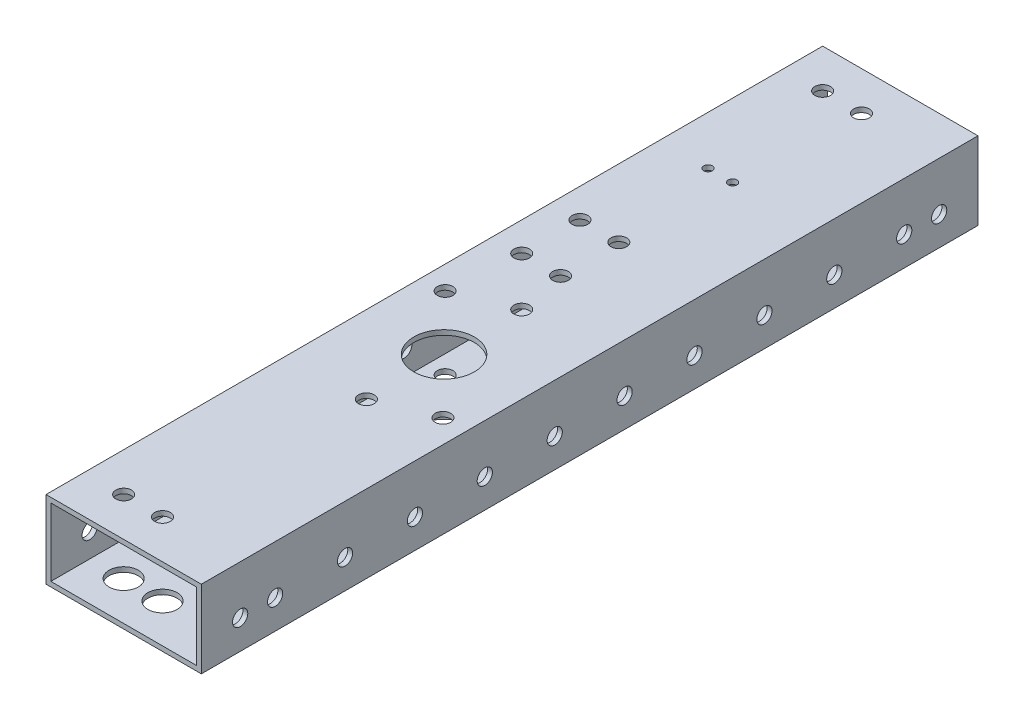
from build123d import *

# Parameters (mm, degrees)
SKETCH1_W           = 50.8
SKETCH1_H           = 25.4
SKETCH1_W_2         = 47.625
SKETCH1_H_2         = 22.225
BOSS_EXTRUDE1_DEPTH = 127
SKETCH3_R           = 2.5527
CUT_EXTRUDE1_DEPTH  = 1.5875
SKETCH5_R           = 4.7625
SKETCH5_R_2         = 2.5527
CUT_EXTRUDE2_DEPTH  = 1.5875
SKETCH6_R           = 2.4892
CUT_EXTRUDE3_DEPTH  = 138.371503595
SKETCH11_R          = 9.906
SKETCH11_R_2        = 2.5527
SKETCH11_R_3        = 1.4224
CUT_EXTRUDE4_DEPTH  = 132.982271537


with BuildPart() as part:
    # Sketch1 → Boss-Extrude1 (new, symmetric)
    with BuildSketch(Plane.XY):
        Rectangle(SKETCH1_W, SKETCH1_H)
        Rectangle(SKETCH1_W_2, SKETCH1_H_2, mode=Mode.SUBTRACT)
    extrude(amount=BOSS_EXTRUDE1_DEPTH, both=True)

    # Sketch3 → Cut-Extrude1 (cut)
    with BuildSketch(Plane(origin=(0, 12.7, 0), x_dir=(1, 0, 0), z_dir=(0, 1, 0))):
        with Locations(Location((-12.7, -114.3, 0), (0, 0, 270))):
            Circle(SKETCH3_R)
        with Locations(Location((0, -114.3, 0), (0, 0, 270))):
            Circle(SKETCH3_R)
        with Locations(Location((-12.7, 114.3, 0), (0, 0, 270))):
            Circle(SKETCH3_R)
        with Locations(Location((0, 114.3, 0), (0, 0, 270))):
            Circle(SKETCH3_R)
    extrude(amount=-CUT_EXTRUDE1_DEPTH, mode=Mode.SUBTRACT)

    # Sketch5 → Cut-Extrude2 (cut)
    with BuildSketch(Plane.XZ.offset(12.7)):
        with Locations(Location((0, -114.3, 0), (0, 0, 270))):
            Circle(SKETCH5_R)
        with Locations(Location((0, -114.3, 0), (0, 0, 90))):
            Circle(SKETCH5_R_2, mode=Mode.SUBTRACT)
        with Locations(Location((0, -114.3, 0), (0, 0, 90))):
            Circle(SKETCH5_R_2)
        with Locations(Location((-12.7, -114.3, 0), (0, 0, 270))):
            Circle(SKETCH5_R)
        with Locations(Location((-12.7, -114.3, 0), (0, 0, 90))):
            Circle(SKETCH5_R_2, mode=Mode.SUBTRACT)
        with Locations(Location((-12.7, -114.3, 0), (0, 0, 90))):
            Circle(SKETCH5_R_2)
        with Locations(Location((0, 114.3, 0), (0, 0, 270))):
            Circle(SKETCH5_R)
        with Locations(Location((0, 114.3, 0), (0, 0, 90))):
            Circle(SKETCH5_R_2, mode=Mode.SUBTRACT)
        with Locations(Location((0, 114.3, 0), (0, 0, 90))):
            Circle(SKETCH5_R_2)
        with Locations(Location((-12.7, 114.3, 0), (0, 0, 270))):
            Circle(SKETCH5_R)
        with Locations(Location((-12.7, 114.3, 0), (0, 0, 90))):
            Circle(SKETCH5_R_2, mode=Mode.SUBTRACT)
        with Locations(Location((-12.7, 114.3, 0), (0, 0, 90))):
            Circle(SKETCH5_R_2)
    extrude(amount=-CUT_EXTRUDE2_DEPTH, mode=Mode.SUBTRACT)

    # Sketch6 → Cut-Extrude3 (cut, through all)
    with BuildSketch(Plane(origin=(25.4, 0, 0), x_dir=(0, 0, -1), z_dir=(1, 0, 0))):
        with Locations((-114.3, -3.175)):
            Circle(SKETCH6_R)
        with Locations((114.3, -3.175)):
            Circle(SKETCH6_R)
        with Locations((-102.87, -3.175)):
            Circle(SKETCH6_R)
        with Locations((-80.01, -3.175)):
            Circle(SKETCH6_R)
        with Locations((-57.15, -3.175)):
            Circle(SKETCH6_R)
        with Locations((-34.29, -3.175)):
            Circle(SKETCH6_R)
        with Locations((-11.43, -3.175)):
            Circle(SKETCH6_R)
        with Locations((11.43, -3.175)):
            Circle(SKETCH6_R)
        with Locations((34.29, -3.175)):
            Circle(SKETCH6_R)
        with Locations((57.15, -3.175)):
            Circle(SKETCH6_R)
        with Locations((80.01, -3.175)):
            Circle(SKETCH6_R)
        with Locations((102.87, -3.175)):
            Circle(SKETCH6_R)
    extrude(amount=-CUT_EXTRUDE3_DEPTH, mode=Mode.SUBTRACT)

    # Sketch11 → Cut-Extrude4 (cut, through all)
    with BuildSketch(Plane(origin=(0, 12.7, 0), x_dir=(1, 0, 0), z_dir=(0, 1, 0))):
        with Locations(Location((0, -22.225, 0), (0, 0, 270))):
            Circle(SKETCH11_R)
        with Locations(Location((0, 3.175, 0), (0, 0, 270))):
            Circle(SKETCH11_R_2)
        with Locations(Location((0, -47.625, 0), (0, 0, 270))):
            Circle(SKETCH11_R_2)
        with Locations(Location((-15.875, 19.05, 0), (0, 0, 270))):
            Circle(SKETCH11_R_2)
        with Locations(Location((-15.875, 38.1, 0), (0, 0, 270))):
            Circle(SKETCH11_R_2)
        with Locations(Location((-3.175, 19.05, 0), (0, 0, 270))):
            Circle(SKETCH11_R_2)
        with Locations(Location((-3.175, 38.1, 0), (0, 0, 270))):
            Circle(SKETCH11_R_2)
        with Locations(Location((-17.78, -4.085771792, 0), (0, 0, 270))):
            Circle(SKETCH11_R_2)
        with Locations(Location((17.78, -40.364228208, 0), (0, 0, 270))):
            Circle(SKETCH11_R_2)
        with Locations(Location((-9.525, 73.66, 0), (0, 0, 270))):
            Circle(SKETCH11_R_3)
        with Locations(Location((-1.524999998, 73.66, 0), (0, 0, 270))):
            Circle(SKETCH11_R_3)
    extrude(amount=-CUT_EXTRUDE4_DEPTH, mode=Mode.SUBTRACT)


solid = part.part
